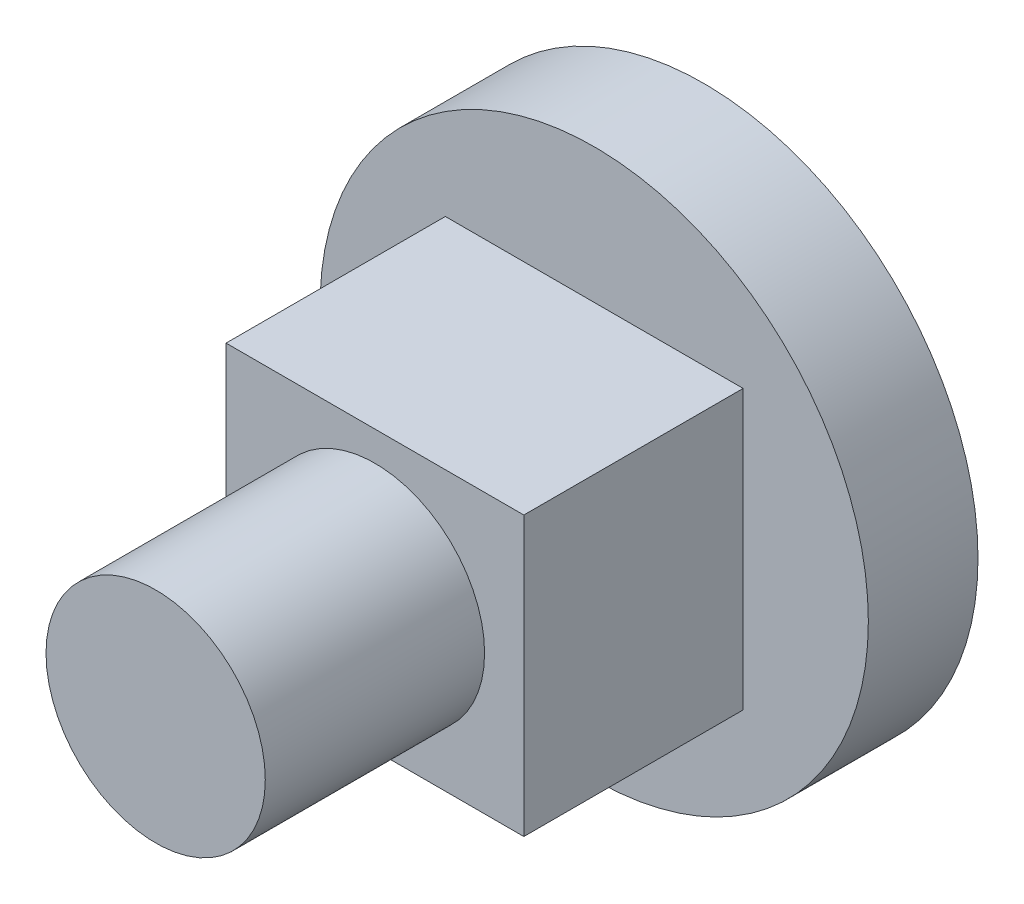
from build123d import *

# Parameters (mm, degrees)
ESQUISSE1_R        = 2.5
BOSS_EXTRU_1_DEPTH = 1
ESQUISSE2_W        = 2.7158457
ESQUISSE2_H        = 2.539681012
BOSS_EXTRU_2_DEPTH = 2
ESQUISSE3_R        = 1
BOSS_EXTRU_3_DEPTH = 2


with BuildPart() as part:
    # Esquisse1 → Boss.-Extru.1 (new body)
    with BuildSketch(Plane.XY):
        Circle(ESQUISSE1_R)
    extrude(amount=BOSS_EXTRU_1_DEPTH)


with BuildPart() as body_2:
    # Esquisse2 → Boss.-Extru.2 (new body)
    with BuildSketch(Plane.XY.offset(1)):
        Rectangle(ESQUISSE2_W, ESQUISSE2_H)
    extrude(amount=BOSS_EXTRU_2_DEPTH)


with BuildPart() as body_3:
    # Esquisse3 → Boss.-Extru.3 (new body)
    with BuildSketch(Plane.XY.offset(3)):
        Circle(ESQUISSE3_R)
    extrude(amount=BOSS_EXTRU_3_DEPTH)


solid = Compound([part.part, body_2.part, body_3.part])
